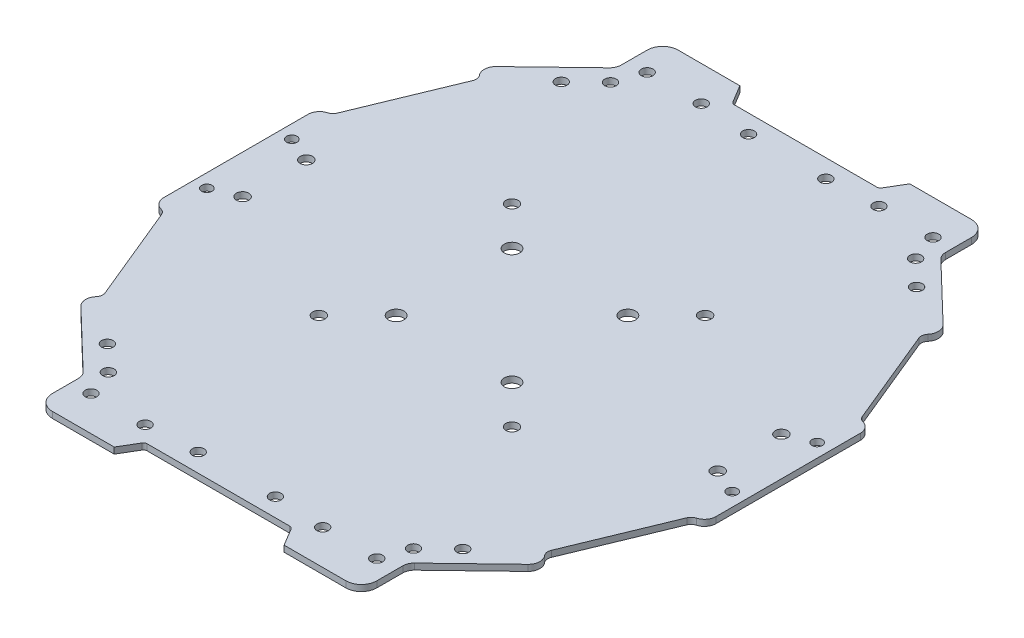
from build123d import *

# Parameters (mm, degrees)
SKETCH1_R        = 1.5
SKETCH1_R_2      = 1.600010398
SKETCH1_R_3      = 1.6
SKETCH1_R_4      = 2
SKETCH1_R_5      = 1.35
EXTRUSION1_DEPTH = 1.6
FILLET1_R        = 1
FILLET2_R        = 4
FILLET3_R        = 3
FILLET4_R        = 3
FILLET5_R        = 2
FILLET6_R        = 2
FILLET7_R        = 3
FILLET8_R        = 3
FILLET9_R        = 2
FILLET10_R       = 2
FILLET11_R       = 3


with BuildPart() as part:
    # Sketch1 → Extrusion1 (new body)
    with BuildSketch(Plane(origin=(0, 0, 0), x_dir=(-1, 0, 0), z_dir=(0, 1, 0))):
        Polygon((59.775158519, 259.059874387), (56.775158519, 264.05987395), (36.775158519, 264.05987395), (36.775158519, 252.05987395), (18.755330752, 234.731117294), (21.527931817, 231.847944851), (10.275158581, 204.559863083), (7.275158519, 204.559863083), (7.275158519, 183.059873956), (7.275158519, 161.559884829), (10.275158581, 161.559884829), (21.527931817, 134.27180306), (18.755330752, 131.388630617), (36.775158519, 114.059873961), (36.775158519, 102.059873961), (56.775158519, 102.059873961), (59.775158519, 107.059873524), (78.775158519, 107.059873524), (97.775158519, 107.059873524), (100.775158519, 102.059873961), (120.775158519, 102.059873961), (120.775158519, 114.059873961), (138.794986286, 131.388630617), (136.022385221, 134.27180306), (147.275158457, 161.559884829), (150.275158519, 161.559884829), (150.275158519, 183.059873956), (150.275158519, 204.559863083), (147.275158457, 204.559863083), (136.022385221, 231.847944851), (138.794986286, 234.731117294), (120.775158519, 252.05987395), (120.775158519, 264.05987395), (100.775158519, 264.05987395), (97.775158519, 259.059874387), (78.775158519, 259.059874387), align=None)
        with Locations((55.775158457, 111.059872631)):
            Circle(SKETCH1_R, mode=Mode.SUBTRACT)
        with Locations((39.275158457, 118.059884829)):
            Circle(SKETCH1_R, mode=Mode.SUBTRACT)
        with Locations((53.775158519, 208.059873956)):
            Circle(SKETCH1_R_2, mode=Mode.SUBTRACT)
        with Locations((53.775158519, 158.059873956)):
            Circle(SKETCH1_R_2, mode=Mode.SUBTRACT)
        with Locations((17.275158457, 174.809872631)):
            Circle(SKETCH1_R_3, mode=Mode.SUBTRACT)
        with Locations((103.775158519, 158.059873956)):
            Circle(SKETCH1_R_2, mode=Mode.SUBTRACT)
        with Locations((93.775158519, 198.059873956)):
            Circle(SKETCH1_R_4, mode=Mode.SUBTRACT)
        with Locations((63.775158519, 198.059873956)):
            Circle(SKETCH1_R_4, mode=Mode.SUBTRACT)
        with Locations((63.775158519, 168.059873956)):
            Circle(SKETCH1_R_4, mode=Mode.SUBTRACT)
        with Locations((93.775158519, 168.059873956)):
            Circle(SKETCH1_R_4, mode=Mode.SUBTRACT)
        with Locations((41.775158457, 255.059863083)):
            Circle(SKETCH1_R, mode=Mode.SUBTRACT)
        with Locations((39.275158457, 248.059863083)):
            Circle(SKETCH1_R, mode=Mode.SUBTRACT)
        with Locations((10.775158457, 194.05987528)):
            Circle(SKETCH1_R_5, mode=Mode.SUBTRACT)
        with Locations((88.775158581, 111.809884829)):
            Circle(SKETCH1_R, mode=Mode.SUBTRACT)
        with Locations((115.775158581, 111.059884829)):
            Circle(SKETCH1_R, mode=Mode.SUBTRACT)
        with Locations((118.275158581, 118.059884829)):
            Circle(SKETCH1_R, mode=Mode.SUBTRACT)
        with Locations((140.275158581, 174.809872631)):
            Circle(SKETCH1_R_3, mode=Mode.SUBTRACT)
        with Locations((115.775158581, 255.059863083)):
            Circle(SKETCH1_R, mode=Mode.SUBTRACT)
        with Locations((88.775158581, 254.309863083)):
            Circle(SKETCH1_R, mode=Mode.SUBTRACT)
        with Locations((140.275158581, 191.30987528)):
            Circle(SKETCH1_R_3, mode=Mode.SUBTRACT)
        with Locations((146.775158581, 194.05987528)):
            Circle(SKETCH1_R_5, mode=Mode.SUBTRACT)
        with Locations((101.775158581, 255.05987528)):
            Circle(SKETCH1_R, mode=Mode.SUBTRACT)
        with Locations((118.275158581, 248.059863083)):
            Circle(SKETCH1_R, mode=Mode.SUBTRACT)
        with Locations((146.775158581, 172.059872631)):
            Circle(SKETCH1_R_5, mode=Mode.SUBTRACT)
        with Locations((101.775158581, 111.059872631)):
            Circle(SKETCH1_R, mode=Mode.SUBTRACT)
        with Locations((17.275158457, 191.30987528)):
            Circle(SKETCH1_R_3, mode=Mode.SUBTRACT)
        with Locations((55.775158457, 255.05987528)):
            Circle(SKETCH1_R, mode=Mode.SUBTRACT)
        with Locations((68.775158457, 254.309863083)):
            Circle(SKETCH1_R, mode=Mode.SUBTRACT)
        with Locations((10.775158457, 172.059872631)):
            Circle(SKETCH1_R_5, mode=Mode.SUBTRACT)
        with Locations((68.775158457, 111.809884829)):
            Circle(SKETCH1_R, mode=Mode.SUBTRACT)
        with Locations((41.775158457, 111.059884829)):
            Circle(SKETCH1_R, mode=Mode.SUBTRACT)
        with Locations((32.775158457, 124.309884829)):
            Circle(SKETCH1_R, mode=Mode.SUBTRACT)
        with Locations((124.775158581, 241.809863083)):
            Circle(SKETCH1_R, mode=Mode.SUBTRACT)
        with Locations((32.775158457, 241.809863083)):
            Circle(SKETCH1_R, mode=Mode.SUBTRACT)
        with Locations((103.775158519, 208.059873956)):
            Circle(SKETCH1_R_2, mode=Mode.SUBTRACT)
        with Locations((124.775158581, 124.309884829)):
            Circle(SKETCH1_R, mode=Mode.SUBTRACT)
    extrude(amount=EXTRUSION1_DEPTH)

    # Fillet1
    fillet1_edges = [part.edges().sort_by_distance(p)[0] for p in [
        (-97.775158519, 0.8, 259.059874387),
        (-97.775158519, 0.8, 107.059873524),
        (-59.775158519, 0.8, 107.059873524),
        (-59.775158519, 0.8, 259.059874387),
    ]]
    fillet(fillet1_edges, radius=FILLET1_R)

    # Fillet2
    fillet2_edges = [part.edges().sort_by_distance(p)[0] for p in [
        (-120.775158519, 0.8, 264.05987395),
        (-120.775158519, 0.8, 102.059873961),
        (-36.775158519, 0.8, 102.059873961),
        (-36.775158519, 0.8, 264.05987395),
    ]]
    fillet(fillet2_edges, radius=FILLET2_R)

    # Fillet3
    fillet3_edges = [part.edges().sort_by_distance(p)[0] for p in [
        (-120.775158519, 0.8, 252.05987395),
        (-120.775158519, 0.8, 114.059873961),
        (-36.775158519, 0.8, 114.059873961),
        (-36.775158519, 0.8, 252.05987395),
    ]]
    fillet(fillet3_edges, radius=FILLET3_R)

    # Fillet4
    fillet4_edges = [part.edges().sort_by_distance(p)[0] for p in [
        (-138.794986286, 0.8, 234.731117294),
    ]]
    fillet(fillet4_edges, radius=FILLET4_R)

    # Fillet5
    fillet5_edges = [part.edges().sort_by_distance(p)[0] for p in [
        (-136.022385221, 0.8, 231.847944851),
    ]]
    fillet(fillet5_edges, radius=FILLET5_R)

    # Fillet6
    fillet6_edges = [part.edges().sort_by_distance(p)[0] for p in [
        (-21.527931817, 0.8, 231.847944851),
    ]]
    fillet(fillet6_edges, radius=FILLET6_R)

    # Fillet7
    fillet7_edges = [part.edges().sort_by_distance(p)[0] for p in [
        (-18.755330752, 0.8, 234.731117294),
    ]]
    fillet(fillet7_edges, radius=FILLET7_R)

    # Fillet8
    fillet8_edges = [part.edges().sort_by_distance(p)[0] for p in [
        (-138.794986286, 0.8, 131.388630617),
        (-18.755330752, 0.8, 131.388630617),
    ]]
    fillet(fillet8_edges, radius=FILLET8_R)

    # Fillet9
    fillet9_edges = [part.edges().sort_by_distance(p)[0] for p in [
        (-21.527931817, 0.8, 134.27180306),
        (-136.022385221, 0.8, 134.27180306),
    ]]
    fillet(fillet9_edges, radius=FILLET9_R)

    # Fillet10
    fillet10_edges = [part.edges().sort_by_distance(p)[0] for p in [
        (-147.275158457, 0.8, 204.559863083),
        (-147.275158457, 0.8, 161.559884829),
        (-10.275158581, 0.8, 161.559884829),
        (-10.275158581, 0.8, 204.559863083),
    ]]
    fillet(fillet10_edges, radius=FILLET10_R)

    # Fillet11
    fillet11_edges = [part.edges().sort_by_distance(p)[0] for p in [
        (-150.275158519, 0.8, 161.559884829),
        (-150.275158519, 0.8, 204.559863083),
        (-7.275158519, 0.8, 204.559863083),
        (-7.275158519, 0.8, 161.559884829),
    ]]
    fillet(fillet11_edges, radius=FILLET11_R)


solid = part.part
